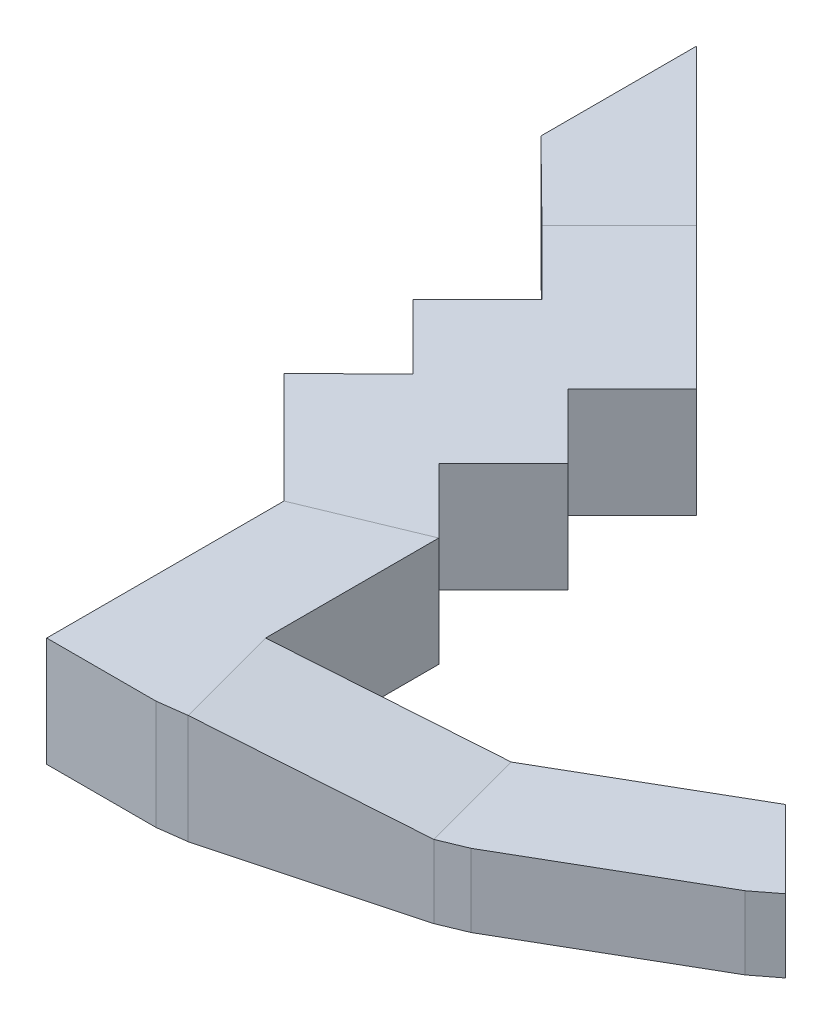
from build123d import *

# Parameters (mm, degrees)
BOSS_EXTRUDE1_DEPTH      = 600
CUT_EXTRUDE9_DEPTH       = 8723.868006427
CUT_EXTRUDE9_DEPTH_BACK  = 8723.868006427
CUT_EXTRUDE_THIN1_DEPTH  = 8723.868006427
CUT_EXTRUDE40_DEPTH      = 400
CUT_EXTRUDE42_DEPTH      = 8272.33671098
CUT_EXTRUDE42_DEPTH_BACK = 8272.33671098
CUT_EXTRUDE43_DEPTH      = 200
CUT_EXTRUDE44_DEPTH      = 8662.204945729
CUT_EXTRUDE44_DEPTH_BACK = 8662.204945729
SKETCH20_W               = 1000
SKETCH20_H               = 600
CUT_EXTRUDE45_DEPTH      = 600
CUT_EXTRUDE46_DEPTH      = 600
BOSS_EXTRUDE2_DEPTH      = 600
BOSS_EXTRUDE3_DEPTH      = 600
BOSS_EXTRUDE4_DEPTH      = 600
BOSS_EXTRUDE5_REACH      = 8720.017
SKETCH27_W               = 600.055718855
SKETCH27_H               = 600
CUT_EXTRUDE47_DEPTH      = 500
CUT_EXTRUDE48_DEPTH      = 500
CUT_EXTRUDE49_DEPTH      = 500


with BuildPart() as part:
    # Sketch1 → Boss-Extrude1 (new body)
    with BuildSketch(Plane(origin=(0, 0, 0), x_dir=(1, 0, 0), z_dir=(0, 1, 0))):
        Polygon((0, 0), (-1000, 0), (-2062.518408918, -284.700949613), (-3015.146353081, -834.700949613), (-3792.963812386, -1612.518408918), (-4570.781271691, -2390.335868223), (-4695.045340403, -2485.687041782), (-5647.673284566, -3035.687041782), (-5792.381857505, -3095.627295285), (-6854.900266423, -3380.328244897), (-7010.191693484, -3400.772749124), (-8010.191693484, -3400.772749124), (-8010.191693484, -2800.772749124), (-7010.191693484, -2800.772749124), (-5947.673284566, -2516.071799511), (-4995.045340403, -1966.071799511), (-4217.227881098, -1188.254340206), (-3439.410421793, -410.436880901), (-3315.146353081, -315.085707342), (-2362.518408918, 234.914292658), (-2217.809835979, 294.854546161), (-1155.291427062, 579.555495773), (-1000, 600), (0, 600), align=None)
    extrude(amount=-BOSS_EXTRUDE1_DEPTH)

    # Sketch7 → Cut-Extrude9 (cut, two sides)
    with BuildSketch(Plane.XY) as cut_extrude9_sk:
        Polygon((-1000, 14081.643483175), (-1000, 0), (-1000, -600), (-2062.518408918, -400), (-3015.146353081, -400), (-3015.146353081, 0), (-3015.146353081, 14081.643483175), (-3015.146353081, 42244.930449524), (-1000, 42244.930449524), align=None)
    extrude(amount=CUT_EXTRUDE9_DEPTH, mode=Mode.SUBTRACT)
    extrude(cut_extrude9_sk.sketch, amount=-CUT_EXTRUDE9_DEPTH_BACK, mode=Mode.SUBTRACT)


with BuildPart() as cut_extrude9_piece_1:
    # of the separate pieces the step leaves, piece 1, a body of its own (cut_extrude9_pieces)
    add(part.part.solids().sort_by_distance((-2062.518408918, -400, 284.700949613))[0])

    # Sketch14 → Cut-Extrude40 (cut)
    with BuildSketch(Plane(origin=(0, -400, 0), x_dir=(1, 0, 0), z_dir=(0, 1, 0))):
        Polygon((-3015.146353081, -834.700949613), (-3439.410421793, -410.436880901), (-3315.146353081, -315.085707342), (-3015.146353081, -141.880626585), align=None)
    extrude(amount=CUT_EXTRUDE40_DEPTH, mode=Mode.SUBTRACT)

    # Sketch17 → Cut-Extrude42 (cut, two sides)
    with BuildSketch(Plane(origin=(-1090.222701734, 0, -1090.222701734), x_dir=(0.7071067811865475, 0, -0.7071067811865477), z_dir=(0.7071067811865477, 0, 0.7071067811865475))) as cut_extrude42_sk:
        Polygon((-4922.253134267, 10770.157285422), (-4922.253134267, 0), (-4922.253134267, -200), (-2722.253134267, -400), (-2722.253134267, 0), (-2722.253134267, 10770.157285422), (-2722.253134267, 32310.471856265), (-4922.253134267, 32310.471856265), align=None)
    extrude(amount=CUT_EXTRUDE42_DEPTH, mode=Mode.SUBTRACT)
    extrude(cut_extrude42_sk.sketch, amount=-CUT_EXTRUDE42_DEPTH_BACK, mode=Mode.SUBTRACT)

    # Sketch18 → Cut-Extrude43 (cut)
    with BuildSketch(Plane(origin=(0, 0, 0), x_dir=(1, 0, 0), z_dir=(0, 1, 0))):
        Polygon((-4570.781271691, -2390.335868223), (-4995.045340403, -1966.071799511), (-5947.673284566, -2516.071799511), (-5792.381857505, -3095.627295285), (-5647.673284566, -3035.687041782), (-4695.045340403, -2485.687041782), align=None)
    extrude(amount=-CUT_EXTRUDE43_DEPTH, mode=Mode.SUBTRACT)

    # Sketch19 → Cut-Extrude44 (cut, two sides)
    with BuildSketch(Plane(origin=(385.890813578, 0, 1440.164122449), x_dir=(0.9659258262890701, 0, -0.2588190451025142), z_dir=(0.2588190451025142, 0, 0.9659258262890701))) as cut_extrude44_sk:
        Polygon((-7496.218532451, 0), (-6396.218532451, -200), (-6396.218532451, 0), align=None)
    extrude(amount=CUT_EXTRUDE44_DEPTH, mode=Mode.SUBTRACT)
    extrude(cut_extrude44_sk.sketch, amount=-CUT_EXTRUDE44_DEPTH_BACK, mode=Mode.SUBTRACT)

    # Sketch20 → Cut-Extrude45 (cut)
    with BuildSketch(Plane(origin=(0, 0, 0), x_dir=(1, 0, 0), z_dir=(0, 1, 0))):
        with Locations((-7510.191693484, -3100.772749124)):
            Rectangle(SKETCH20_W, SKETCH20_H)
    extrude(amount=-CUT_EXTRUDE45_DEPTH, mode=Mode.SUBTRACT)

    # Sketch22 → Boss-Extrude2 (add)
    with BuildSketch(Plane(origin=(0, 0, 0), x_dir=(1, 0, 0), z_dir=(0, 1, 0))):
        Polygon((-7010.191693484, -3400.772749124), (-7610.191693484, -3400.772749124), (-7610.191693484, -2099.772749124), (-7010.191693484, -1850.772749124), (-7010.191693484, -2800.772749124), align=None)
    extrude(amount=-BOSS_EXTRUDE2_DEPTH)

    # Sketch23 → Boss-Extrude3 (add)
    with BuildSketch(Plane(origin=(0, 0, 0), x_dir=(1, 0, 0), z_dir=(0, 1, 0))):
        Polygon((-7010.191693484, -1850.772749124), (-7363.745084077, -1497.219358531), (-7010.191693484, -1143.665967937), (-7363.745084077, -790.112577344), (-7010.191693484, -436.559186751), (-7369.52720003, -77.223680205), (-7793.791268742, 347.040388507), (-7858.719830908, 270.547594436), (-8212.273221501, -83.005796158), (-7858.719830908, -436.559186751), (-8212.273221501, -790.112577344), (-7858.719830908, -1143.665967937), (-8216.472118741, -1493.492323867), (-7610.191693484, -2099.772749124), align=None)
    extrude(amount=-BOSS_EXTRUDE3_DEPTH)

    # Sketch27 → Boss-Extrude5 (add, up to next)
    with BuildSketch(Plane(origin=(-4176.549949048, 0, -4064.239704482), x_dir=(0.6974051569050131, 0, -0.7166770870638283), z_dir=(0.7166770870638283, 0, 0.6974051569050131)), mode=Mode.PRIVATE) as boss_extrude5_sk1:
        with Locations((-5486.74218736, -300)):
            Rectangle(SKETCH27_W, SKETCH27_H)
    boss_extrude5_tool1 = extrude(boss_extrude5_sk1.sketch, amount=BOSS_EXTRUDE5_REACH, mode=Mode.PRIVATE) - cut_extrude9_piece_1.part


with BuildPart() as cut_extrude9_piece_2:
    # of the separate pieces the step leaves, piece 2, a body of its own (cut_extrude9_pieces)
    add(part.part.solids().sort_by_distance((0, 0, 0))[0])

    # Sketch8 → Cut-Extrude-Thin1 (cut, through all)
    with BuildSketch(Plane.XY):
        Polygon((-1000, 0), (-1000, -600), (0, -600), (0, 0), (-10, 0), (-10, -590), (-990, -590), (-990, 0), align=None)
        Polygon((-4695.045340403, 0), (-4695.045340403, -200), (-4570.781271691, -200), (-3015.146353081, -400), (-3013.871199655, -390.081634019), (-4570.141081915, -190), (-4685.045340403, -190), (-4685.045340403, 0), align=None)
    extrude(amount=-CUT_EXTRUDE_THIN1_DEPTH, mode=Mode.SUBTRACT)

    # Sketch21 → Cut-Extrude46 (cut)
    with BuildSketch(Plane(origin=(0, 0, 0), x_dir=(1, 0, 0), z_dir=(0, 1, 0))):
        Polygon((0, 0), (-10, 600), (-990, 600), (-1000, 0), align=None)
    extrude(amount=-CUT_EXTRUDE46_DEPTH, mode=Mode.SUBTRACT)


with BuildPart() as body_2:
    # Sketch24 → Boss-Extrude4 (new body)
    with BuildSketch(Plane(origin=(0, 0, 0), x_dir=(1, 0, 0), z_dir=(0, 1, 0))):
        Polygon((-8212.273221501, -83.005796158), (-8639.443107058, 338.362406502), (-8639.443107058, 1192.692226823), (-7793.791268742, 347.040388507), align=None)
    extrude(amount=-BOSS_EXTRUDE4_DEPTH)


with BuildPart() as cut_extrude9_piece_1_1:
    add(cut_extrude9_piece_1.part)

    add(body_2.part)  # Boss-Extrude5 merges body 2
    add(boss_extrude5_tool1.solids().sort_by_distance((-8003.032245, -300, -132.017296))[0])

    # Sketch38 → Cut-Extrude47 (cut)
    with BuildSketch(Plane.XZ.offset(600)):
        Polygon((-4570.781271691, 2390.335868223), (-4995.045340403, 1966.071799511), (-3439.410421793, 410.436880901), (-3315.146353081, 315.085707342), (-2217.809835979, -294.854546161), (-2062.518408918, -336.464758633), (-1000, -600), (-1000, 0), (-2062.518408918, 284.700949613), (-3015.146353081, 834.700949613), align=None)
    extrude(amount=-CUT_EXTRUDE47_DEPTH, mode=Mode.SUBTRACT)


with BuildPart() as cut_extrude47_piece_1:
    # of the separate pieces the step leaves, piece 1, a body of its own (cut_extrude47_pieces)
    add(cut_extrude9_piece_1_1.part.solids().sort_by_distance((-4570.781271691, -600, 2390.335868223))[0])


with BuildPart() as cut_extrude47_piece_2:
    # of the separate pieces the step leaves, piece 2, a body of its own (cut_extrude47_pieces)
    add(cut_extrude9_piece_1_1.part.solids().sort_by_distance((-2362.518408918, -600, -234.914292658))[0])

    # Sketch40 → Cut-Extrude49 (cut)
    with BuildSketch(Plane(origin=(0, -600, 0), x_dir=(-1, 0, 0), z_dir=(0, -1, 0))):
        Polygon((2362.518408918, 234.914292658), (2217.809835979, 294.854546161), (3315.146353081, -315.085707342), align=None)
    extrude(amount=-CUT_EXTRUDE49_DEPTH, mode=Mode.SUBTRACT)


with BuildPart() as cut_extrude47_piece_3:
    # of the separate pieces the step leaves, piece 3, a body of its own (cut_extrude47_pieces)
    add(cut_extrude9_piece_1_1.part.solids().sort_by_distance((-1155.291427062, -570.769179008, -579.555495773))[0])

    # Sketch39 → Cut-Extrude48 (cut)
    with BuildSketch(Plane(origin=(0, -600, 0), x_dir=(-1, 0, 0), z_dir=(0, -1, 0))):
        Polygon((1155.291427062, 579.555495773), (1000, 600), (2062.518408918, 336.464758633), align=None)
    extrude(amount=-CUT_EXTRUDE48_DEPTH, mode=Mode.SUBTRACT)


solid = cut_extrude47_piece_1.part
